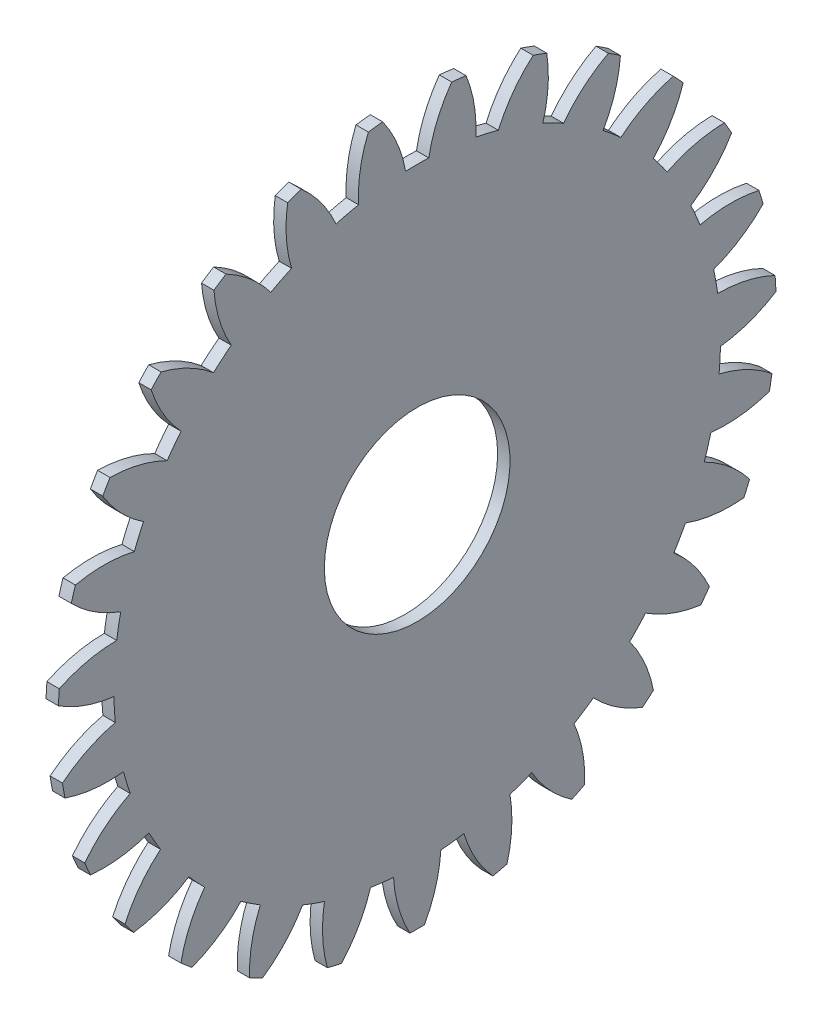
from build123d import *

# Parameters (mm, degrees)
BASPROSKE_W     = 3
BASPROSKE_H     = 87
TOOTHCUT_DEPTH  = 124.07314898
TEETHCUTS_COUNT = 27
TEETHCUTS_ANGLE = 346.666666667
BORSKE_R        = 22.5
BORE_DEPTH      = 50.0000508


with BuildPart() as part:
    # BasProSke → Base-Revolve (revolve)
    with BuildSketch(Plane(origin=(0, 0, 0), x_dir=(1, 0, 0), z_dir=(0, 1, 0)), mode=Mode.PRIVATE) as base_revolve_sk:
        with Locations((1.5, 43.5)):
            Rectangle(BASPROSKE_W, BASPROSKE_H)
    revolve(base_revolve_sk.sketch.rotate(Axis((-10, 0, 0), (1, 0, 0)), 180), axis=Axis((-10, 0, 0), (1, 0, 0)))

    # TooCutSke → ToothCut (cut, through all)
    with BuildSketch(Plane(origin=(0, 0, 0), x_dir=(0, 0, -1), z_dir=(1, 0, 0))):
        with BuildLine():
            ThreePointArc((2.811849911, 73.445193859), (0, 73.499), (-2.811849911, 73.445193859))
            ThreePointArc((-2.811849911, 73.445193859), (-4.857182833, 80.344135525), (-8.374789903, 86.621493518))
            ThreePointArc((-8.374789903, 86.621493518), (0, 87.0254), (8.374789903, 86.621493518))
            ThreePointArc((8.374789903, 86.621493518), (4.857182833, 80.344135525), (2.811849911, 73.445193859))
        make_face()
    toothcut = extrude(amount=TOOTHCUT_DEPTH, mode=Mode.SUBTRACT)

    # TeethCuts: ToothCut ×27 about axis
    teethcuts_axis = Axis((-10, 0, 0), (1, 0, 0))
    for i in range(1, TEETHCUTS_COUNT):
        add(toothcut.rotate(teethcuts_axis, i * TEETHCUTS_ANGLE / (TEETHCUTS_COUNT - 1)), mode=Mode.SUBTRACT)

    # BorSke → Bore (cut, symmetric)
    with BuildSketch(Plane(origin=(0, 0, 0), x_dir=(0, 0, -1), z_dir=(1, 0, 0))):
        with Locations(Location((0, 0, 0), (0, 0, 180))):
            Circle(BORSKE_R)
    extrude(amount=BORE_DEPTH, both=True, mode=Mode.SUBTRACT)


solid = part.part
